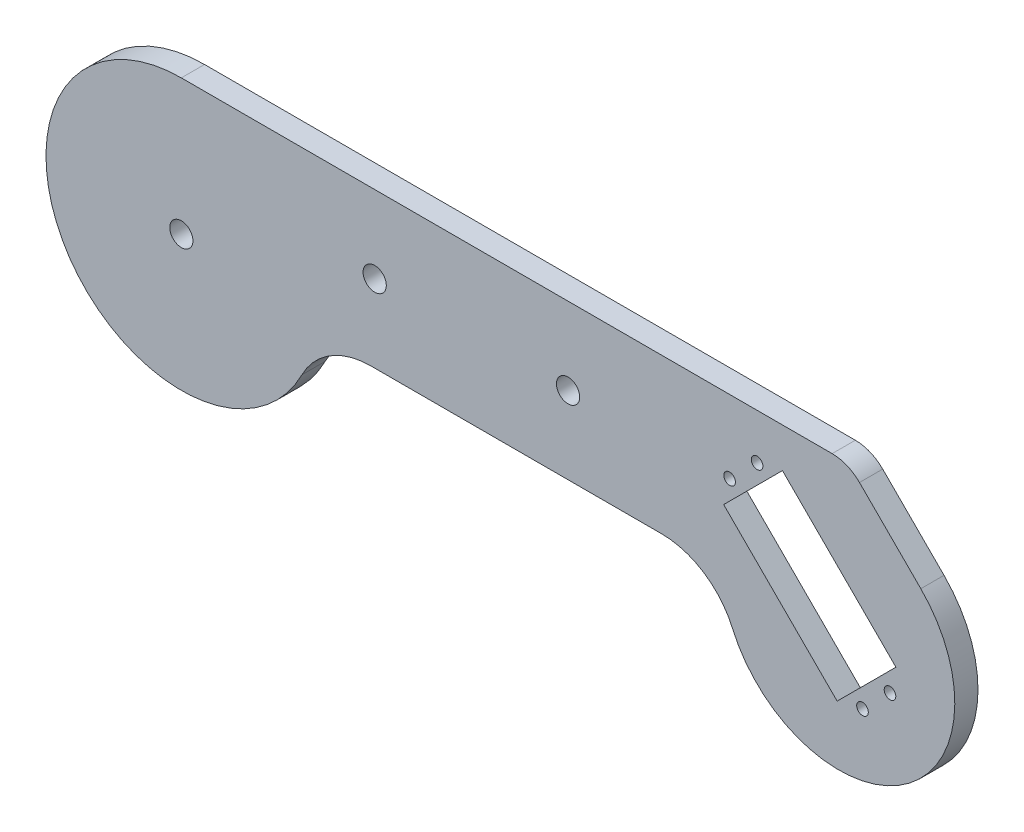
from build123d import *

# Parameters (mm, degrees)
SKETCH1_R           = 3
SKETCH1_R_2         = 1.5
BOSS_EXTRUDE1_DEPTH = 6


with BuildPart() as part:
    # Sketch1 → Boss-Extrude1 (new body)
    with BuildSketch(Plane.XY):
        with BuildLine():
            Line((0, 35), (168.284271247, 35))
            ThreePointArc((168.284271247, 35), (172.111105571, 34.238795325), (175.355339059, 32.071067812))
            Line((175.355339059, 32.071067812), (191.213203436, 16.213203436))
            ThreePointArc((191.213203436, 16.213203436), (186.901061777, -29.786167732), (142.50454583, -17))
            ThreePointArc((142.50454583, -17), (135.128694201, -8.266799469), (124.17424305, -5))
            Line((124.17424305, -5), (48.989794856, -5))
            ThreePointArc((48.989794856, -5), (38.545135498, -7.943942692), (31.175323999, -15.909090909))
            ThreePointArc((31.175323999, -15.909090909), (-29.84810029, -18.278153875), (0, 35))
        make_face()
        Circle(SKETCH1_R, mode=Mode.SUBTRACT)
        with Locations((50, 15)):
            Circle(SKETCH1_R, mode=Mode.SUBTRACT)
        with Locations((100, 15)):
            Circle(SKETCH1_R, mode=Mode.SUBTRACT)
        with Locations((183.241017493, -11.134594342)):
            Circle(SKETCH1_R_2, mode=Mode.SUBTRACT)
        with Locations((176.134594342, -18.241017493)):
            Circle(SKETCH1_R_2, mode=Mode.SUBTRACT)
        with Locations((141.769204776, 16.124372073)):
            Circle(SKETCH1_R_2, mode=Mode.SUBTRACT)
        with Locations((148.875627927, 23.230795224)):
            Circle(SKETCH1_R_2, mode=Mode.SUBTRACT)
        Polygon((155.434043323, 24.768752473), (184.778974742, -4.576178946), (169.576178946, -19.778974742), (140.231247527, 9.565956677), align=None, mode=Mode.SUBTRACT)
    extrude(amount=BOSS_EXTRUDE1_DEPTH)


solid = part.part
